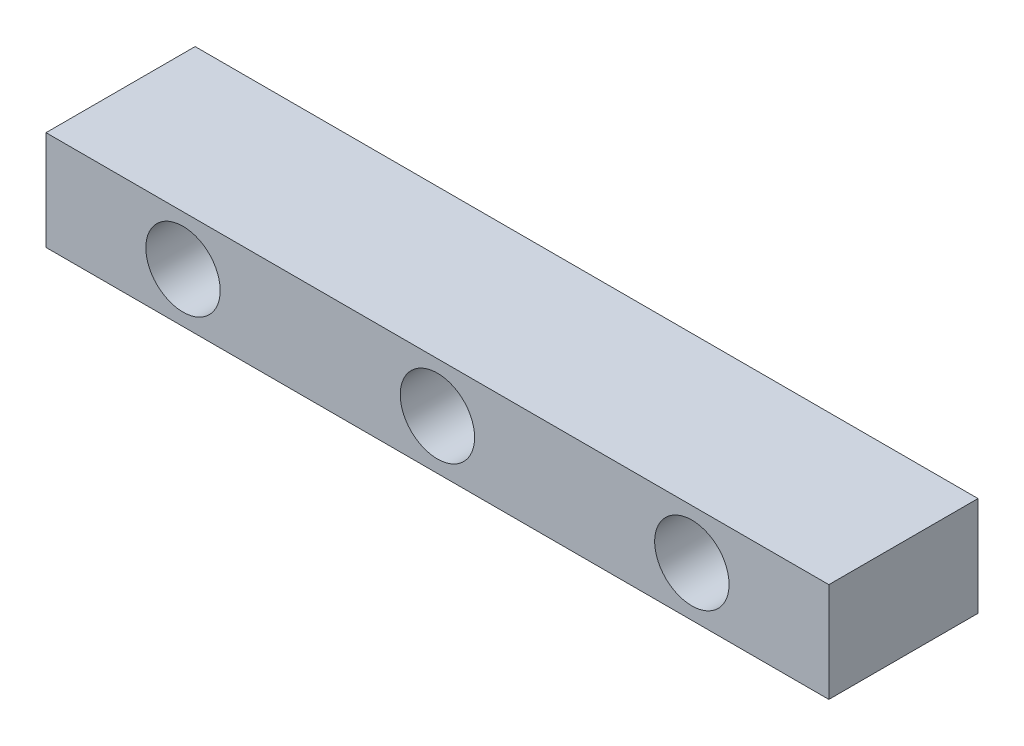
from build123d import *

# Parameters (mm, degrees)
SKETCH1_W           = 400
SKETCH1_H           = 76.2
BOSS_EXTRUDE1_DEPTH = 50.8
SKETCH2_R           = 19
CUT_EXTRUDE1_DEPTH  = 76.2


with BuildPart() as part:
    # Sketch1 → Boss-Extrude1 (new body)
    with BuildSketch(Plane(origin=(0, 0, 0), x_dir=(1, 0, 0), z_dir=(0, 1, 0))):
        with Locations((200, 38.1)):
            Rectangle(SKETCH1_W, SKETCH1_H)
    extrude(amount=BOSS_EXTRUDE1_DEPTH)

    # Sketch2 → Cut-Extrude1 (cut)
    with BuildSketch(Plane.XY):
        with Locations((70, 25.4)):
            Circle(SKETCH2_R)
        with Locations((200, 25.4)):
            Circle(SKETCH2_R)
        with Locations((330, 25.4)):
            Circle(SKETCH2_R)
    extrude(amount=-CUT_EXTRUDE1_DEPTH, mode=Mode.SUBTRACT)


solid = part.part
